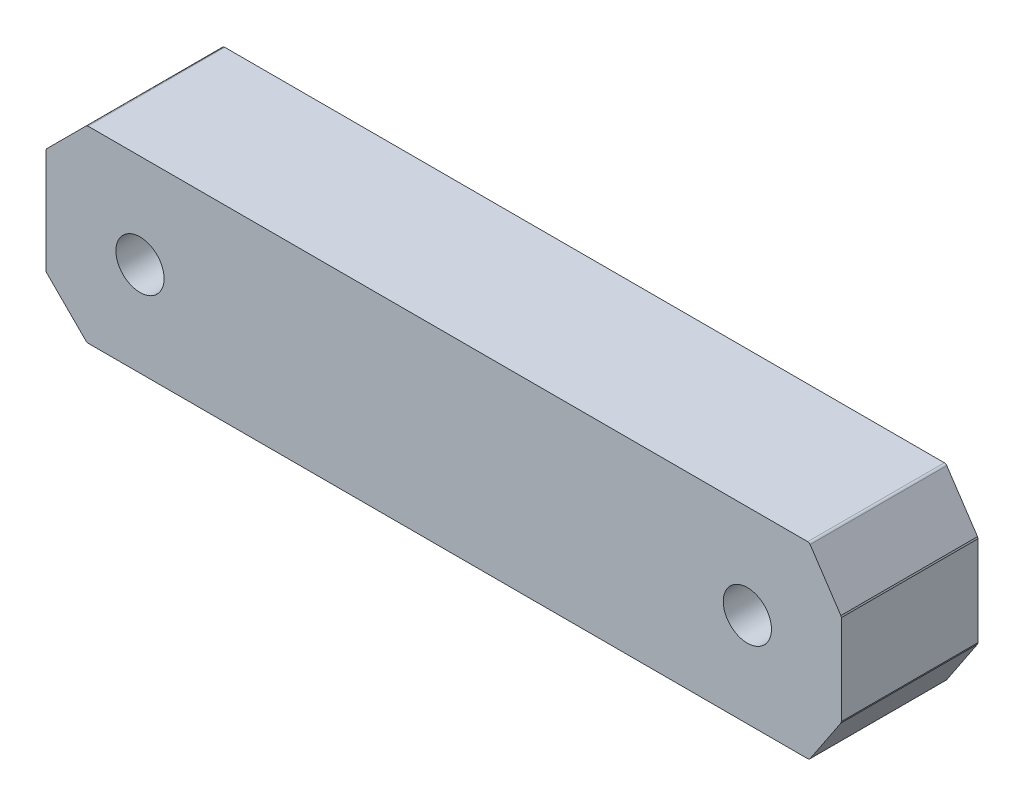
from build123d import *

# Parameters (mm, degrees)
SKETCH1_R           = 1.666
BOSS_EXTRUDE1_DEPTH = 9.45


with BuildPart() as part:
    # Sketch1 → Boss-Extrude1 (new body)
    with BuildSketch(Plane.XY):
        with BuildLine():
            Line((-24.730151519, -6.441421356), (-27.441421356, -3.730151519))
            ThreePointArc((-27.441421356, -3.730151519), (-27.484775907, -3.665266849), (-27.5, -3.588730163))
            Line((-27.5, -3.588730163), (-27.5, 3.588730163))
            ThreePointArc((-27.5, 3.588730163), (-27.484775907, 3.665266849), (-27.441421356, 3.730151519))
            Line((-27.441421356, 3.730151519), (-24.730151519, 6.441421356))
            ThreePointArc((-24.730151519, 6.441421356), (-24.665266849, 6.484775907), (-24.588730163, 6.5))
            Line((-24.588730163, 6.5), (25.17448832, 6.5))
            ThreePointArc((25.17448832, 6.5), (25.268868885, 6.476330114), (25.340909677, 6.410923091))
            Line((25.340909677, 6.410923091), (27.466421356, 3.221951957))
            Line((27.466421356, 3.221951957), (27.5, 3.111028865))
            Line((27.5, 3.111028865), (27.5, -3.111028865))
            Line((27.5, -3.111028865), (27.466421356, -3.221951957))
            Line((27.466421356, -3.221951957), (25.340909677, -6.410923091))
            ThreePointArc((25.340909677, -6.410923091), (25.268868885, -6.476330114), (25.17448832, -6.5))
            Line((25.17448832, -6.5), (-24.588730163, -6.5))
            ThreePointArc((-24.588730163, -6.5), (-24.665266849, -6.484775907), (-24.730151519, -6.441421356))
        make_face()
        with Locations((21, 0)):
            Circle(SKETCH1_R, mode=Mode.SUBTRACT)
        with Locations((-21, 0)):
            Circle(SKETCH1_R, mode=Mode.SUBTRACT)
    extrude(amount=BOSS_EXTRUDE1_DEPTH)


solid = part.part
